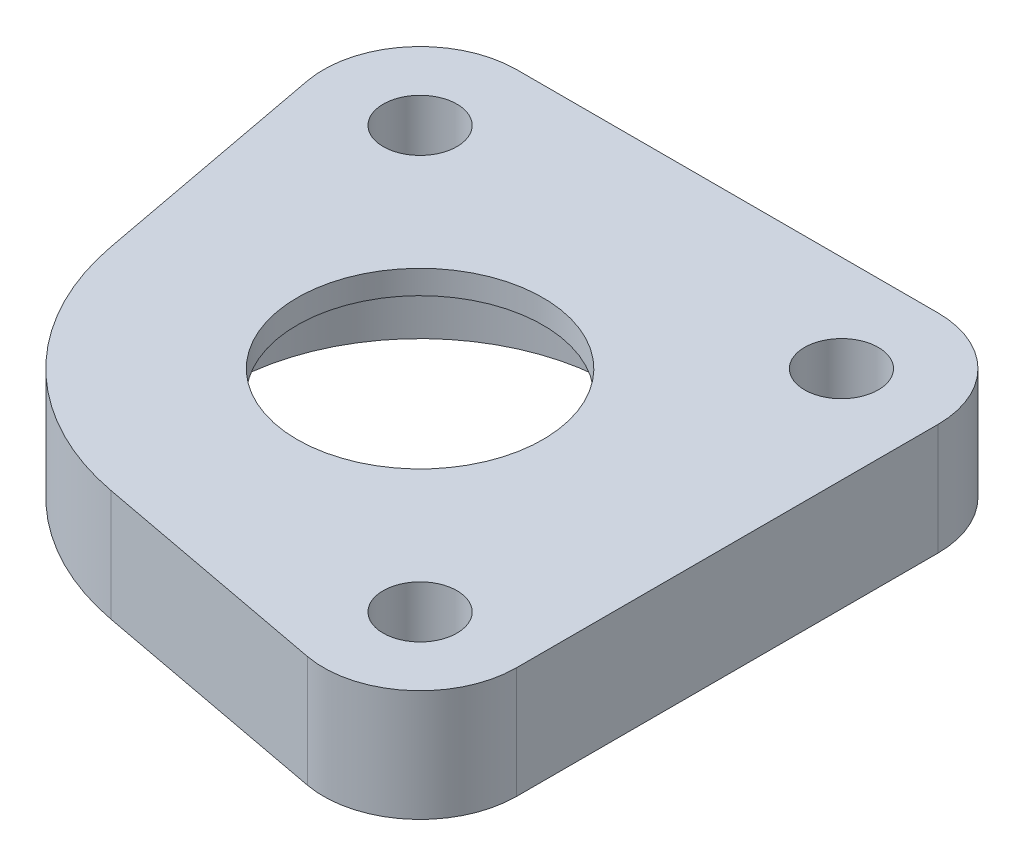
from build123d import *

# Parameters (mm, degrees)
SKETCH1_R             = 7
BOSS_EXTRUDE1_DEPTH   = 6.35
SKETCH1_3_R           = 11.075
CUT_EXTRUDE1_DEPTH    = 5
M5X0_8_TAPPED_HOLE1_D = 4.2


with BuildPart() as part:
    # Sketch1 → Boss-Extrude1 (new body)
    with BuildSketch(Plane(origin=(0, 0, 0), x_dir=(1, 0, 0), z_dir=(0, 1, 0))):
        with BuildLine():
            Line((-12, 17.5), (12, 17.5))
            ThreePointArc((12, 17.5), (15.889087297, 15.889087297), (17.5, 12))
            Line((17.5, 12), (17.5, -12))
            ThreePointArc((17.5, -12), (15.511287903, -16.233303351), (10.983324632, -17.405217035))
            Line((10.983324632, -17.405217035), (-2.78661476, -14.81520851))
            ThreePointArc((-2.78661476, -14.81520851), (-10.659634726, -10.659634726), (-14.81520851, -2.78661476))
            Line((-14.81520851, -2.78661476), (-17.405217035, 10.983324632))
            ThreePointArc((-17.405217035, 10.983324632), (-16.233303351, 15.511287903), (-12, 17.5))
        make_face()
        Circle(SKETCH1_R, mode=Mode.SUBTRACT)
    extrude(amount=BOSS_EXTRUDE1_DEPTH)

    # Sketch1_3 → Cut-Extrude1 (cut)
    with BuildSketch(Plane(origin=(0, 0, 0), x_dir=(1, 0, 0), z_dir=(0, 1, 0))):
        Circle(SKETCH1_3_R)
    extrude(amount=CUT_EXTRUDE1_DEPTH, mode=Mode.SUBTRACT)

    # M5x0.8 Tapped Hole1 (through all)
    with Locations(Plane(origin=(12, 6.35, -12), x_dir=(0, 0, 1), z_dir=(0, 1, 0))):
        with Locations((0, 0), (24, 0), (0, -24)):
            Hole(M5X0_8_TAPPED_HOLE1_D / 2)


solid = part.part
